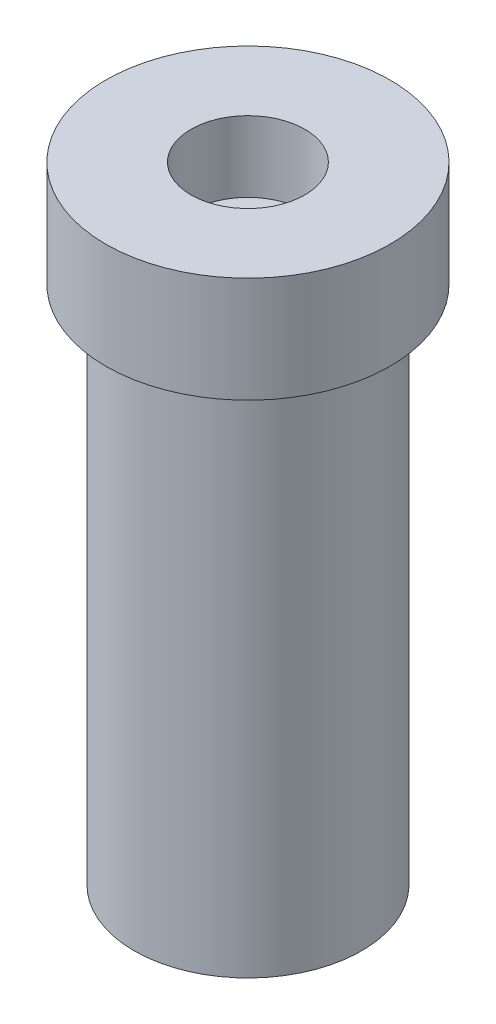
from build123d import *


with BuildPart() as part:
    # Sketch1 → Revolve1 (revolve)
    with BuildSketch(Plane.XY):
        Polygon((0, 0), (1.75, 0), (1.75, 8), (2.185923493, 8), (2.185923493, 9.624585263), (0.875, 9.624585263), (0.875, 8.536413651), (0, 8.536413651), align=None)
    revolve(axis=Axis((0, 11.540862321, 0), (0, -1, 0)))


solid = part.part
